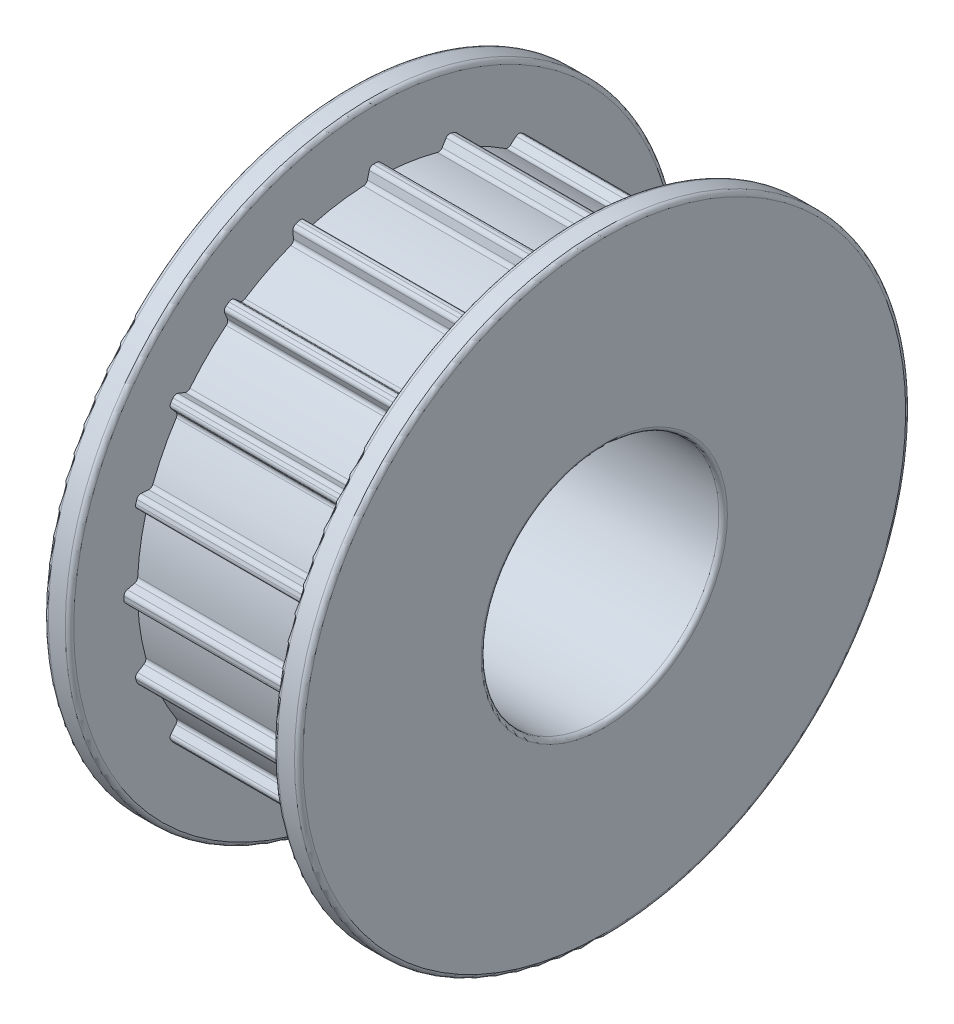
from build123d import *

# Parameters (mm, degrees)
FILLET1_R                = 0.25
BOSS_EXTRUDE1_DEPTH      = 6
FILLET2_R                = 0.25
CIRPATTERN1_COUNT        = 20
FILLET2_OF_CIRPATTERN1_R = 0.25


with BuildPart() as part:
    # Sketch1 → Revolve1 (revolve)
    with BuildSketch(Plane.XY):
        Polygon((-7.5, 7), (7.5, 7), (7.5, 18), (6, 18), (6, 14), (-6, 14), (-6, 18), (-7.5, 18), align=None)
    revolve(axis=Axis((-101.206340592, 0, 0), (1, 0, 0)))

    # Fillet1
    fillet1_edges = [part.edges().sort_by_distance(p)[0] for p in [
        (7.5, -18, 0),
        (7.5, -7, 0),
        (-7.5, -7, 0),
        (-7.5, -18, 0),
        (-6, -18, 0),
        (6, -18, 0),
    ]]
    fillet(fillet1_edges, radius=FILLET1_R)

    # Sketch2 → Boss-Extrude1 (add, symmetric)
    with BuildSketch(Plane(origin=(0, 0, 0), x_dir=(0, 0, -1), z_dir=(1, 0, 0))):
        Polygon((0.3, 14.79106858), (-0.3, 14.79106858), (-0.5, 13.99106858), (-0.5, 13.79106858), (0.5, 13.79106858), (0.5, 13.99106858), align=None)
    boss_extrude1 = extrude(amount=BOSS_EXTRUDE1_DEPTH, both=True)

    # Fillet2
    fillet2_edges = [part.edges().sort_by_distance(p)[0] for p in [
        (0, 13.99106858, -0.5),
        (0, 14.79106858, -0.3),
        (0, 14.79106858, 0.3),
        (0, 13.99106858, 0.5),
    ]]
    fillet(fillet2_edges, radius=FILLET2_R)

    # CirPattern1: Boss-Extrude1 ×20 about axis
    cirpattern1_axis = Axis((0, 0, 0), (1, 0, 0))
    for i in range(1, CIRPATTERN1_COUNT):
        add(boss_extrude1.rotate(cirpattern1_axis, i * 360 / CIRPATTERN1_COUNT))

    # Fillet2 of CirPattern1
    fillet2_of_cirpattern1_edges = [part.edges().sort_by_distance(p)[0] for p in [
        (0, 13.46080544, 3.847949702),
        (0, 14.159847254, 4.285374601),
        (0, 13.974437057, 4.856008511),
        (0, 13.151788445, 4.799006219),
        (0, 11.612904877, 7.819235278),
        (0, 12.142561422, 8.451266878),
        (0, 11.78989027, 8.936677075),
        (0, 11.025119624, 8.628252272),
        (0, 8.628252272, 11.025119624),
        (0, 8.936677075, 11.78989027),
        (0, 8.451266878, 12.142561422),
        (0, 7.819235278, 11.612904877),
        (0, 4.799006219, 13.151788445),
        (0, 4.856008511, 13.974437057),
        (0, 4.285374601, 14.159847254),
        (0, 3.847949702, 13.46080544),
        (0, 0.5, 13.99106858),
        (0, 0.3, 14.79106858),
        (0, -0.3, 14.79106858),
        (0, -0.5, 13.99106858),
        (0, -3.847949702, 13.46080544),
        (0, -4.285374601, 14.159847254),
        (0, -4.856008511, 13.974437057),
        (0, -4.799006219, 13.151788445),
        (0, -7.819235278, 11.612904877),
        (0, -8.451266878, 12.142561422),
        (0, -8.936677075, 11.78989027),
        (0, -8.628252272, 11.025119624),
        (0, -11.025119624, 8.628252272),
        (0, -11.78989027, 8.936677075),
        (0, -12.142561422, 8.451266878),
        (0, -11.612904877, 7.819235278),
        (0, -13.151788445, 4.799006219),
        (0, -13.974437057, 4.856008511),
        (0, -14.159847254, 4.285374601),
        (0, -13.46080544, 3.847949702),
        (0, -13.99106858, 0.5),
        (0, -14.79106858, 0.3),
        (0, -14.79106858, -0.3),
        (0, -13.99106858, -0.5),
        (0, -13.46080544, -3.847949702),
        (0, -14.159847254, -4.285374601),
        (0, -13.974437057, -4.856008511),
        (0, -13.151788445, -4.799006219),
        (0, -11.612904877, -7.819235278),
        (0, -12.142561422, -8.451266878),
        (0, -11.78989027, -8.936677075),
        (0, -11.025119624, -8.628252272),
        (0, -8.628252272, -11.025119624),
        (0, -8.936677075, -11.78989027),
        (0, -8.451266878, -12.142561422),
        (0, -7.819235278, -11.612904877),
        (0, -4.799006219, -13.151788445),
        (0, -4.856008511, -13.974437057),
        (0, -4.285374601, -14.159847254),
        (0, -3.847949702, -13.46080544),
        (0, -0.5, -13.99106858),
        (0, -0.3, -14.79106858),
        (0, 0.3, -14.79106858),
        (0, 0.5, -13.99106858),
        (0, 3.847949702, -13.46080544),
        (0, 4.285374601, -14.159847254),
        (0, 4.856008511, -13.974437057),
        (0, 4.799006219, -13.151788445),
        (0, 7.819235278, -11.612904877),
        (0, 8.451266878, -12.142561422),
        (0, 8.936677075, -11.78989027),
        (0, 8.628252272, -11.025119624),
        (0, 11.025119624, -8.628252272),
        (0, 11.78989027, -8.936677075),
        (0, 12.142561422, -8.451266878),
        (0, 11.612904877, -7.819235278),
        (0, 13.151788445, -4.799006219),
        (0, 13.974437057, -4.856008511),
        (0, 14.159847254, -4.285374601),
        (0, 13.46080544, -3.847949702),
    ]]
    fillet(fillet2_of_cirpattern1_edges, radius=FILLET2_OF_CIRPATTERN1_R)


solid = part.part
